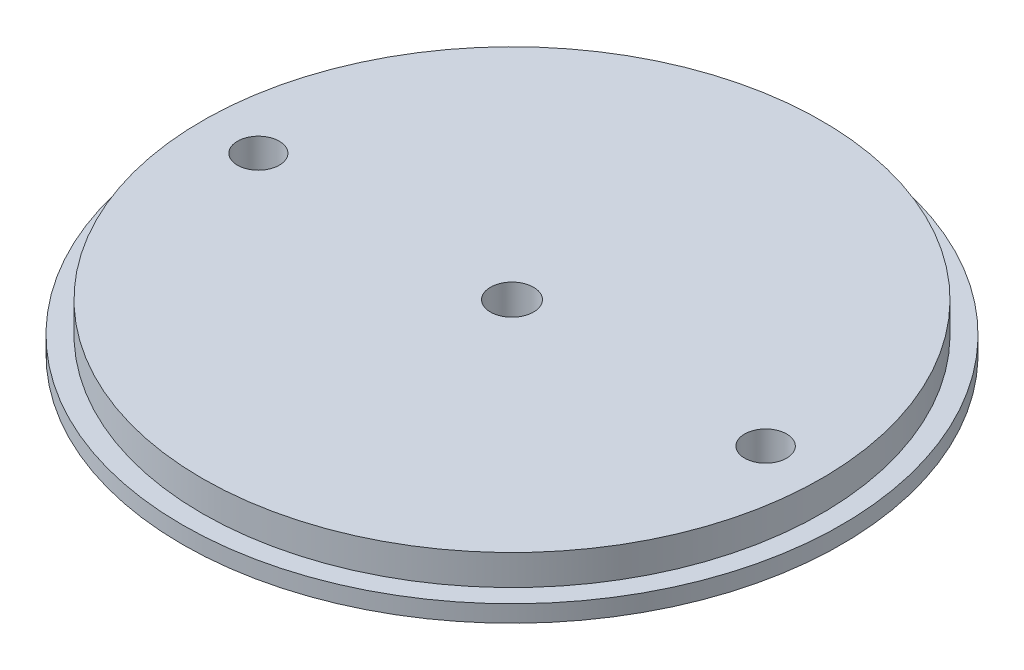
from build123d import *

# Parameters (mm, degrees)
SKETCH1_R           = 50.4825
BOSS_EXTRUDE1_DEPTH = 2.5908
SKETCH2_R           = 47.4472
BOSS_EXTRUDE2_DEPTH = 4.6482
SKETCH3_R           = 3.2
SKETCH3_R_2         = 3.22
SKETCH3_R_3         = 3.302
CUT_EXTRUDE1_DEPTH  = 8.239


with BuildPart() as part:
    # Sketch1 → Boss-Extrude1 (new body)
    with BuildSketch(Plane(origin=(0, 0, 0), x_dir=(1, 0, 0), z_dir=(0, 1, 0))):
        Circle(SKETCH1_R)
    extrude(amount=BOSS_EXTRUDE1_DEPTH)

    # Sketch2 → Boss-Extrude2 (add)
    with BuildSketch(Plane(origin=(0, 2.5908, 0), x_dir=(1, 0, 0), z_dir=(0, 1, 0))):
        Circle(SKETCH2_R)
    extrude(amount=BOSS_EXTRUDE2_DEPTH)

    # Sketch3 → Cut-Extrude1 (cut, through all)
    with BuildSketch(Plane.XZ):
        with Locations((-38.852, 0)):
            Circle(SKETCH3_R)
        with Locations((38.85200002, 0)):
            Circle(SKETCH3_R_2)
        Circle(SKETCH3_R_3)
    extrude(amount=-CUT_EXTRUDE1_DEPTH, mode=Mode.SUBTRACT)


solid = part.part
